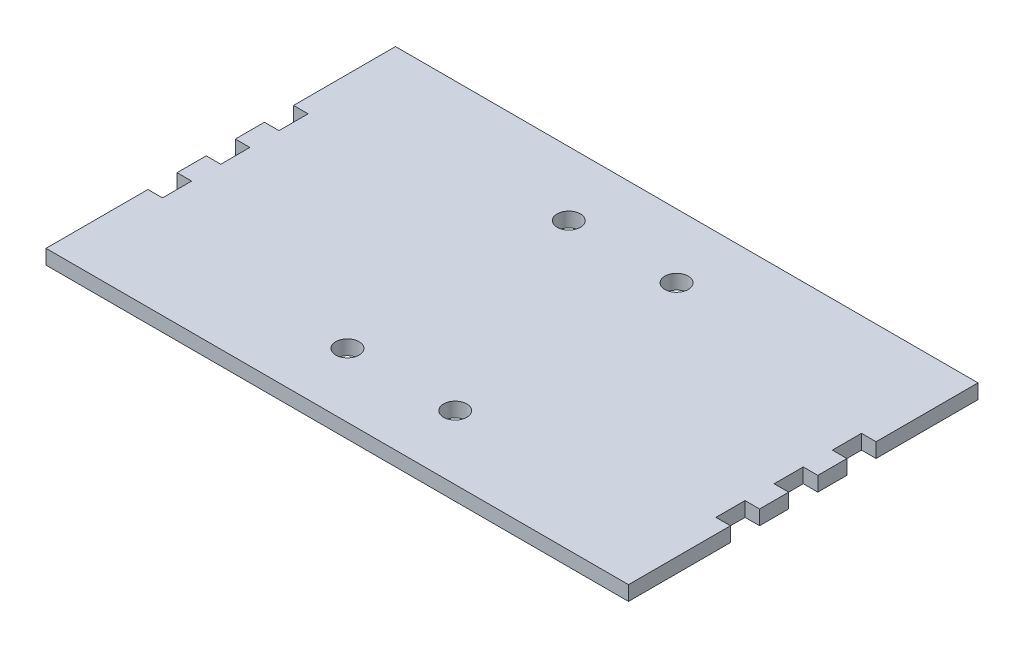
from build123d import *

# Parameters (mm, degrees)
SKETCH_1_W          = 200
SKETCH_1_H          = 120
EXTRUDE_1_DEPTH     = 5
SKETCH_2_W          = 5
SKETCH_2_H          = 10
CUT_EXTRUDE_1_DEPTH = 5
SKETCH_3_R          = 4
CUT_EXTRUDE_2_DEPTH = 6


with BuildPart() as part:
    # 草图1 → 凸台-拉伸1 (new body)
    with BuildSketch(Plane(origin=(0, 0, 0), x_dir=(1, 0, 0), z_dir=(0, 1, 0))):
        Rectangle(SKETCH_1_W, SKETCH_1_H)
    extrude(amount=EXTRUDE_1_DEPTH)

    # 草图2 → 切除-拉伸1 (cut)
    with BuildSketch(Plane(origin=(0, 5, 0), x_dir=(1, 0, 0), z_dir=(0, 1, 0))):
        with Locations((97.5, 0)):
            Rectangle(SKETCH_2_W, SKETCH_2_H)
        with Locations((-97.5, 0)):
            Rectangle(SKETCH_2_W, SKETCH_2_H)
        with Locations((-97.5, -20)):
            Rectangle(SKETCH_2_W, SKETCH_2_H)
        with Locations((-97.5, 20)):
            Rectangle(SKETCH_2_W, SKETCH_2_H)
        with Locations((97.5, -20)):
            Rectangle(SKETCH_2_W, SKETCH_2_H)
        with Locations((97.5, 20)):
            Rectangle(SKETCH_2_W, SKETCH_2_H)
    extrude(amount=-CUT_EXTRUDE_1_DEPTH, mode=Mode.SUBTRACT)

    # 草图3 → 切除-拉伸2 (cut, through all)
    with BuildSketch(Plane(origin=(0, 5, 0), x_dir=(1, 0, 0), z_dir=(0, 1, 0))):
        with Locations((-18.5, 38)):
            Circle(SKETCH_3_R)
        with Locations((18.5, 38)):
            Circle(SKETCH_3_R)
        with Locations((18.5, -38)):
            Circle(SKETCH_3_R)
        with Locations((-18.5, -38)):
            Circle(SKETCH_3_R)
    extrude(amount=-CUT_EXTRUDE_2_DEPTH, mode=Mode.SUBTRACT)


solid = part.part
